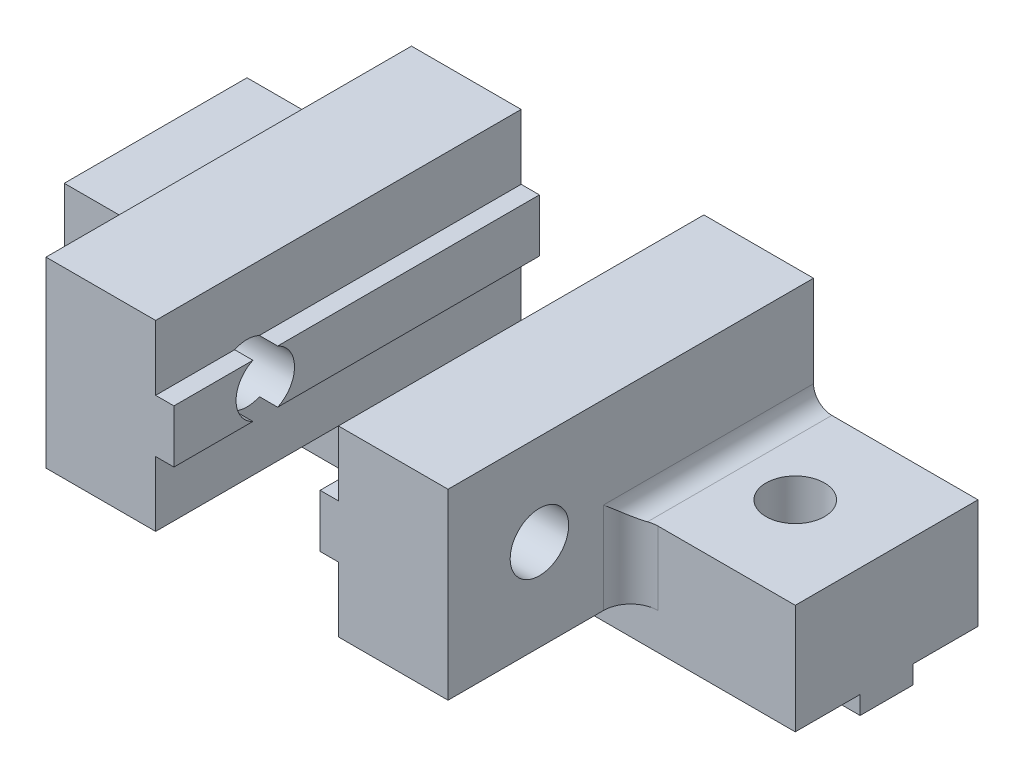
from build123d import *

# Parameters (mm, degrees)
MAIN_DEPTH                   = 20
ESQUISSE4_W                  = 20
ESQUISSE4_H                  = 2.9
VERTICALGUIDANCE_DEPTH       = 1
VERTICALHOLE_DEPTH           = 28.730849248
VERTICALHOLE_DEPTH_BACK      = 28.730849248
ESQUISSE2_R                  = 1.6
ESQUISSE5_W                  = 15
ESQUISSE5_H                  = 2.9
HORIZONTALGUIDANCE_DEPTH     = 1
HORIZONTALHOLE_DEPTH         = 26.961510106
HORIZONTALHOLE_DEPTH_BACK    = 26.961510106
ESQUISSE3_R                  = 1.6
ENL_V_MAT_EXTRU_4_DEPTH      = 26.961510106
ENL_V_MAT_EXTRU_4_DEPTH_BACK = 26.961510106
ESQUISSE9_W                  = 9
ESQUISSE9_H                  = 10
SKETCH1_W                    = 10
SKETCH1_H                    = 2
CUT_EXTRUDE1_DEPTH           = 29.284271247
CONG_2_R                     = 1.5


with BuildPart() as part:
    # Esquisse1 → Main (new body)
    with BuildSketch(Plane.XY):
        with BuildLine():
            Line((0, 0), (15, 0))
            Line((15, 0), (15, 6))
            Line((15, 6), (7, 6))
            ThreePointArc((7, 6), (6.292893219, 6.292893219), (6, 7))
            Line((6, 7), (6, 12))
            Line((6, 12), (0, 12))
            Line((0, 12), (0, 0))
        make_face()
    extrude(amount=MAIN_DEPTH)

    # Esquisse4 → VerticalGuidance (add)
    with BuildSketch(Plane.ZY):
        with Locations((10, 7)):
            Rectangle(ESQUISSE4_W, ESQUISSE4_H)
    extrude(amount=VERTICALGUIDANCE_DEPTH)

    # Esquisse2 → VerticalHole (cut, two sides: drawn at the far end of the back side and taken through both)
    with BuildSketch(Plane.ZY.offset(-VERTICALHOLE_DEPTH_BACK)):
        with Locations((15, 7)):
            Circle(ESQUISSE2_R)
    extrude(amount=VERTICALHOLE_DEPTH + VERTICALHOLE_DEPTH_BACK, mode=Mode.SUBTRACT)

    # Esquisse5 → HorizontalGuidance (add)
    with BuildSketch(Plane(origin=(0, 0, 0), x_dir=(-1, 0, 0), z_dir=(0, -1, 0))):
        with Locations((-7.5, -5)):
            Rectangle(ESQUISSE5_W, ESQUISSE5_H)
    extrude(amount=HORIZONTALGUIDANCE_DEPTH)

    # Esquisse3 → HorizontalHole (cut, two sides: drawn at the far end of the back side and taken through both)
    with BuildSketch(Plane.XZ.offset(-6).offset(-HORIZONTALHOLE_DEPTH_BACK)):
        with Locations((10, 5)):
            Circle(ESQUISSE3_R)
    extrude(amount=HORIZONTALHOLE_DEPTH + HORIZONTALHOLE_DEPTH_BACK, mode=Mode.SUBTRACT)

    # Esquisse9 → Enlèv. mat.-Extru.4 (cut, two sides: drawn at the far end of the back side and taken through both)
    with BuildSketch(Plane(origin=(0, 6, 0), x_dir=(1, 0, 0), z_dir=(0, 1, 0)).offset(-ENL_V_MAT_EXTRU_4_DEPTH_BACK)):
        with Locations((10.5, -15)):
            Rectangle(ESQUISSE9_W, ESQUISSE9_H)
    extrude(amount=ENL_V_MAT_EXTRU_4_DEPTH + ENL_V_MAT_EXTRU_4_DEPTH_BACK, mode=Mode.SUBTRACT)

    # Sketch1 → Cut-Extrude1 (cut, through all)
    with BuildSketch(Plane(origin=(15, 0, 0), x_dir=(0, 0, -1), z_dir=(1, 0, 0))):
        with Locations((-15, 1)):
            Rectangle(SKETCH1_W, SKETCH1_H)
    extrude(amount=-CUT_EXTRUDE1_DEPTH, mode=Mode.SUBTRACT)

    # Congé2
    cong_2_edges = [part.edges().sort_by_distance(p)[0] for p in [
        (6, 4.5, 10),
    ]]
    fillet(cong_2_edges, radius=CONG_2_R)


with BuildPart() as body_2:
    # Mirror1: mirrored copy
    add(part.part.mirror(Plane(origin=(-5, 0, 0), x_dir=(0, 0, 1), z_dir=(1, 0, 0))))


solid = Compound([part.part, body_2.part])
